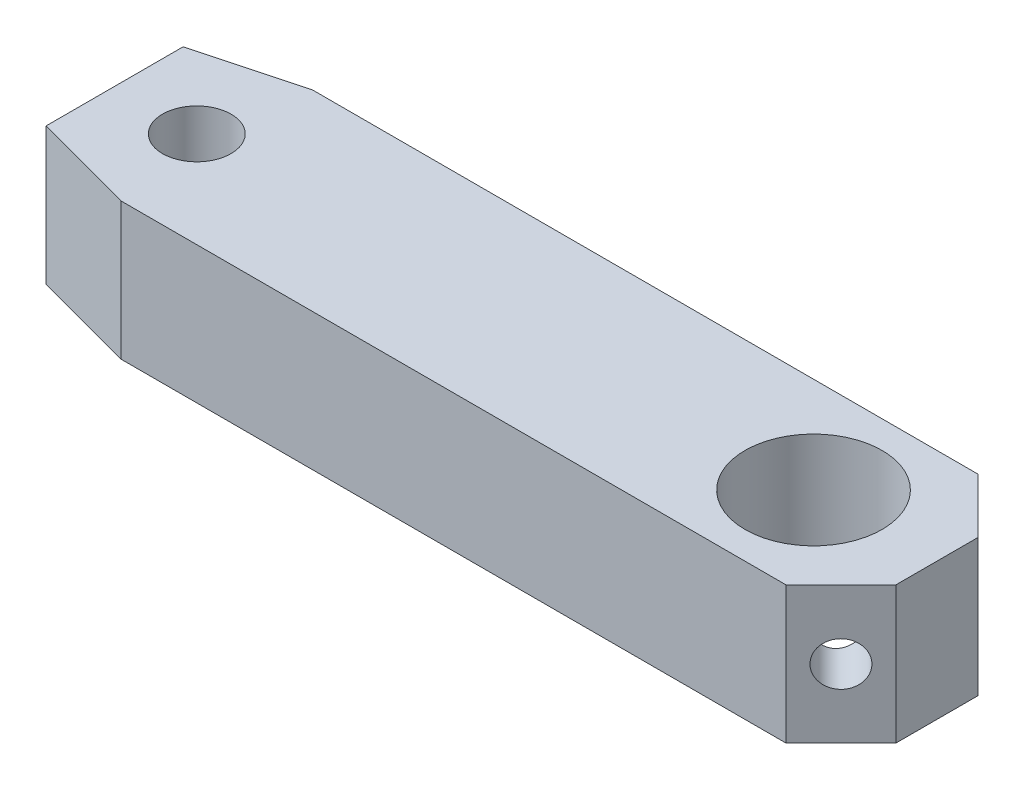
from build123d import *

# Parameters (mm, degrees)
BLOCK_R                = 2.5
BOSS_EXTRUDE1_DEPTH    = 5
M3_TAPPED_HOLE1_D      = 2.5
M2_TAPPED_HOLE1_REACH  = 27.251
M2_TAPPED_HOLE1_BORE_R = 0.8


with BuildPart() as part:
    # block → Boss-Extrude1 (new body)
    with BuildSketch(Plane(origin=(0, 0, 0), x_dir=(1, 0, 0), z_dir=(0, 1, 0))):
        Polygon((0.732050808, 3.5), (25, 3.5), (27, 1.5), (27, -1.5), (25, -3.5), (0.732050808, -3.5), (-3, -2.5), (-3, 2.5), align=None)
        with Locations(Location((22.5, 0, 0), (0, 0, 270))):
            Circle(BLOCK_R, mode=Mode.SUBTRACT)
    extrude(amount=-BOSS_EXTRUDE1_DEPTH)

    # M3 Tapped Hole1 (through all)
    with Locations(Plane(origin=(0, 0, 0), x_dir=(1, 0, 0), z_dir=(0, 1, 0))):
        with Locations((0, 0)):
            Hole(M3_TAPPED_HOLE1_D / 2)

    # M2 Tapped Hole1 bore → M2 Tapped Hole1 (cut, up to next)
    with BuildSketch(Plane(origin=(14.25, 0, -14.25), x_dir=(-0.7071067811865465, 0, -0.7071067811865486), z_dir=(0.7071067811865486, 0, -0.7071067811865465)), mode=Mode.PRIVATE) as m2_tapped_hole1_sk1:
        with Locations((-16.617009358, -2.5)):
            Circle(M2_TAPPED_HOLE1_BORE_R)
    m2_tapped_hole1_tool1 = extrude(m2_tapped_hole1_sk1.sketch, amount=-M2_TAPPED_HOLE1_REACH, mode=Mode.PRIVATE) & part.part
    m2_tapped_hole1 = m2_tapped_hole1_tool1.solids().sort_by_distance((26, -2.5, -2.5))[0]
    add(m2_tapped_hole1, mode=Mode.SUBTRACT)

    # Mirror1: M2 Tapped Hole1 across plane
    add(m2_tapped_hole1.mirror(Plane.XY), mode=Mode.SUBTRACT)


solid = part.part
